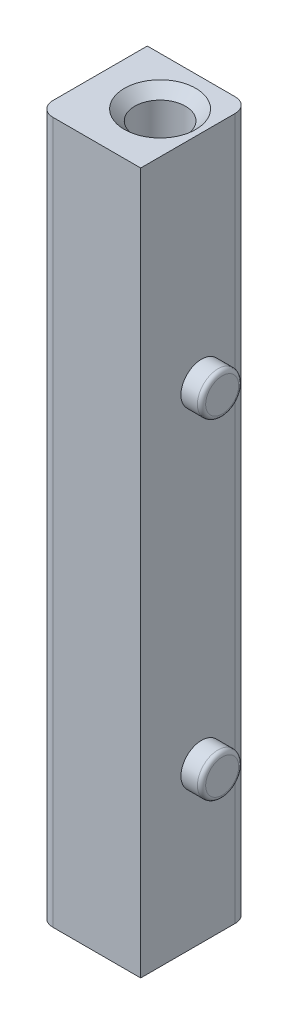
from build123d import *

# Parameters (mm, degrees)
SKETCH1_W                = 12.5984
SKETCH1_H                = 13.4112
BOSS_EXTRUDE1_DEPTH      = 46.99
BOSS_EXTRUDE1_DEPTH_BACK = 39.37
SKETCH2_R                = 3.1242
CUT_EXTRUDE1_DEPTH       = 87.36
SKETCH4_R                = 2.54
BOSS_EXTRUDE2_DEPTH      = 2.54
FILLET2_R                = 0.508
FILLET2_OF_MIRROR1_R     = 0.508
FILLET1_R                = 1.778
CHAMFER1_SIZE            = 1.27


with BuildPart() as part:
    # Sketch1 → Boss-Extrude1 (new body, two sides)
    with BuildSketch(Plane(origin=(0, 0, 0), x_dir=(1, 0, 0), z_dir=(0, 1, 0))) as boss_extrude1_sk:
        with Locations((-1.1938, -0.7874)):
            Rectangle(SKETCH1_W, SKETCH1_H)
    extrude(amount=BOSS_EXTRUDE1_DEPTH)
    extrude(boss_extrude1_sk.sketch, amount=-BOSS_EXTRUDE1_DEPTH_BACK)

    # Sketch2 → Cut-Extrude1 (cut, through all)
    with BuildSketch(Plane(origin=(0, 46.99, 0), x_dir=(1, 0, 0), z_dir=(0, 1, 0))):
        with Locations(Location((0, 0, 0), (0, 0, 270))):  # turned: the seam where the file's is
            Circle(SKETCH2_R)
    extrude(amount=-CUT_EXTRUDE1_DEPTH, mode=Mode.SUBTRACT)

    # Sketch4 → Boss-Extrude2 (add)
    with BuildSketch(Plane(origin=(5.1054, 0, 0), x_dir=(0, 0, -1), z_dir=(1, 0, 0))):
        with Locations((0, -20.32)):
            Circle(SKETCH4_R)
    boss_extrude2 = extrude(amount=BOSS_EXTRUDE2_DEPTH)

    # Fillet2
    fillet2_edges = [part.edges().sort_by_distance(p)[0] for p in [
        (7.6454, -20.32, 2.54),
    ]]
    fillet(fillet2_edges, radius=FILLET2_R)

    # Mirror1: Boss-Extrude2 across plane
    add(boss_extrude2.mirror(Plane.ZX))

    # Fillet2 of Mirror1
    fillet2_of_mirror1_edges = [part.edges().sort_by_distance(p)[0] for p in [
        (7.6454, 20.32, 2.54),
    ]]
    fillet(fillet2_of_mirror1_edges, radius=FILLET2_OF_MIRROR1_R)

    # Fillet1
    fillet1_edges = [part.edges().sort_by_distance(p)[0] for p in [
        (5.1054, 3.81, -5.9182),
        (-7.493, 3.81, 7.493),
    ]]
    fillet(fillet1_edges, radius=FILLET1_R)

    # Chamfer1
    chamfer1_edges = [part.edges().sort_by_distance(p)[0] for p in [
        (0, 46.99, -3.1242),
    ]]
    chamfer(chamfer1_edges, length=CHAMFER1_SIZE)


solid = part.part
